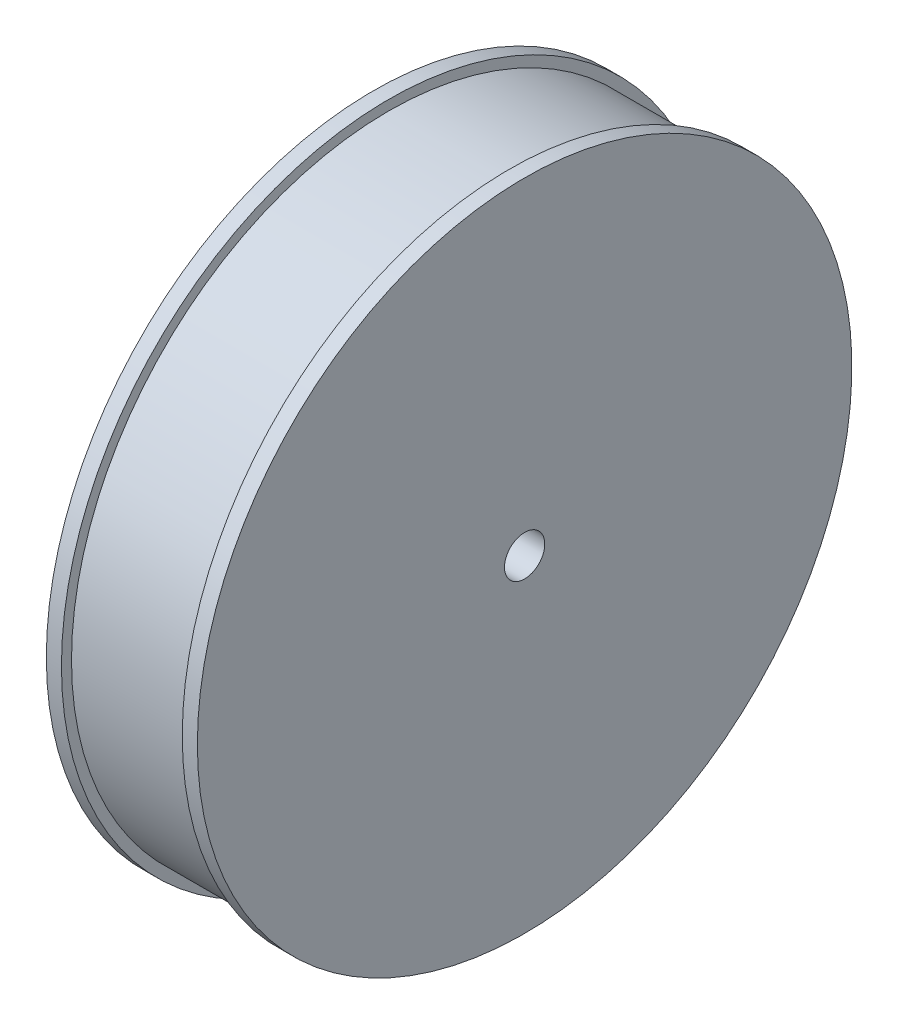
from build123d import *


with BuildPart() as part:
    # Sketch1 → Revolve1 (revolve)
    with BuildSketch(Plane.XY):
        Polygon((12, 65), (15, 65), (15, 4), (-15, 4), (-15, 65), (-12, 65), (-12, 63), (12, 63), align=None)
    revolve(axis=Axis((-15, 0, 0), (1, 0, 0)))


solid = part.part
